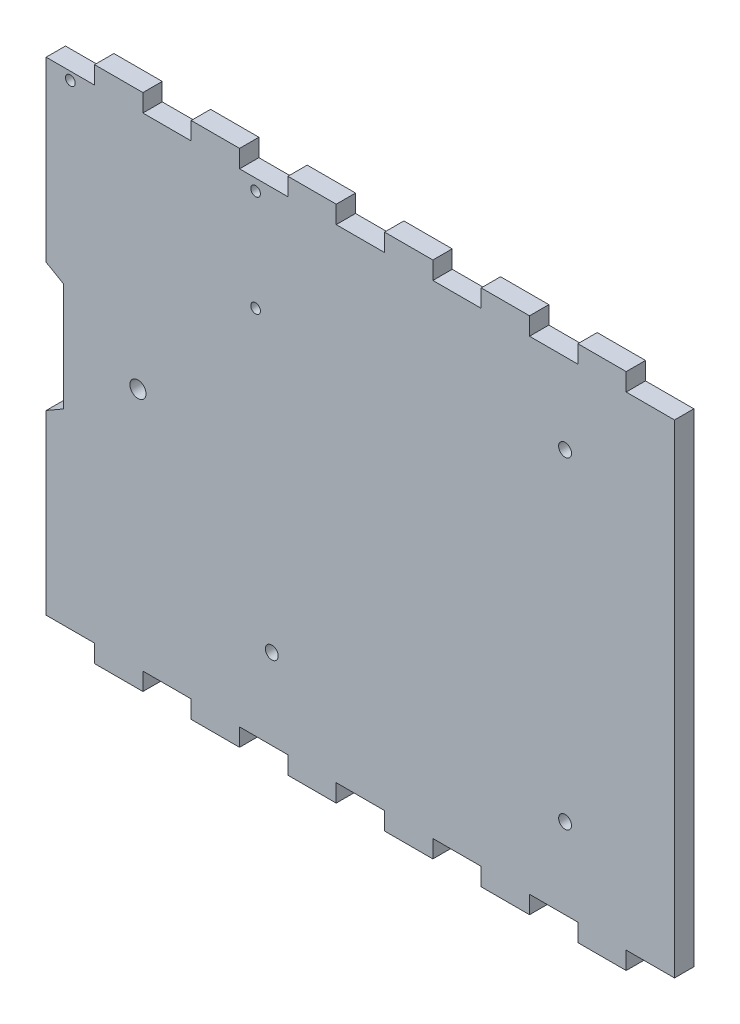
from build123d import *

# Parameters (mm, degrees)
MODEL_R             = 2.5
MODEL_R_2           = 2
MODEL_R_3           = 1.5
BOSS_EXTRUDE1_DEPTH = 6


with BuildPart() as part:
    # Model → Boss-Extrude1 (new body)
    with BuildSketch(Plane.XY):
        Polygon((206.699050252, 163.437183165), (206.699050252, 13.437183165), (191.699050252, 13.437183165), (191.699050252, 7.937183165), (176.699050252, 7.937183165), (176.699050252, 13.437183165), (161.699050252, 13.437183165), (161.699050252, 7.937183165), (146.699050252, 7.937183165), (146.699050252, 13.437183165), (131.699050252, 13.437183165), (131.699050252, 7.937183165), (116.699050252, 7.937183165), (116.699050252, 13.437183165), (101.699050252, 13.437183165), (101.699050252, 7.937183165), (86.699050252, 7.937183165), (86.699050252, 13.437183165), (71.699050252, 13.437183165), (71.699050252, 7.937183165), (56.699050252, 7.937183165), (56.699050252, 13.437183165), (41.699050252, 13.437183165), (41.699050252, 7.937183165), (26.699050252, 7.937183165), (26.699050252, 13.437183165), (11.668968128, 13.437183165), (11.668968128, 68.469250485), (17.008612601, 71.552095659), (17.008612601, 105.223573885), (11.668968128, 108.306419059), (11.668968128, 163.437183165), (26.699050252, 163.437183165), (26.699050252, 168.937183165), (41.699050252, 168.937183165), (41.699050252, 163.437183165), (56.699050252, 163.437183165), (56.699050252, 168.937183165), (71.699050252, 168.937183165), (71.699050252, 163.437183165), (86.699050252, 163.437183165), (86.699050252, 168.937183165), (101.699050252, 168.937183165), (101.699050252, 163.437183165), (116.699050252, 163.437183165), (116.699050252, 168.937183165), (131.699050252, 168.937183165), (131.699050252, 163.437183165), (146.699050252, 163.437183165), (146.699050252, 168.937183165), (161.699050252, 168.937183165), (161.699050252, 163.437183165), (176.699050252, 163.437183165), (176.699050252, 168.937183165), (191.699050252, 168.937183165), (191.699050252, 163.437183165), align=None)
        with Locations((40.168968128, 88.437183165)):
            Circle(MODEL_R, mode=Mode.SUBTRACT)
        with Locations((172.731128361, 138.437183165)):
            Circle(MODEL_R_2, mode=Mode.SUBTRACT)
        with Locations((81.699050252, 38.437183165)):
            Circle(MODEL_R_2, mode=Mode.SUBTRACT)
        with Locations((172.731128361, 38.437183165)):
            Circle(MODEL_R_2, mode=Mode.SUBTRACT)
        with Locations((76.668968128, 128.437183165)):
            Circle(MODEL_R_3, mode=Mode.SUBTRACT)
        with Locations((76.668968128, 159.937183165)):
            Circle(MODEL_R_3, mode=Mode.SUBTRACT)
        with Locations((19.18400919, 160.937183165)):
            Circle(MODEL_R_3, mode=Mode.SUBTRACT)
    extrude(amount=BOSS_EXTRUDE1_DEPTH)


solid = part.part
